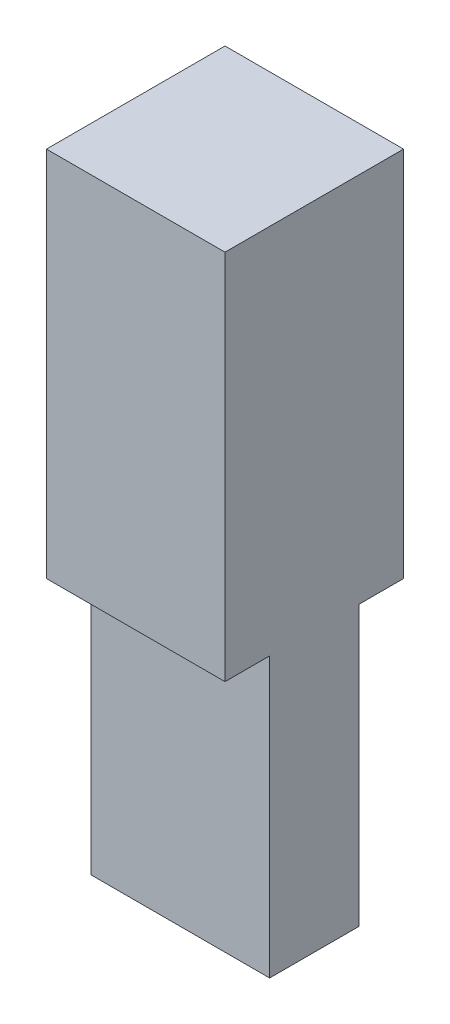
from build123d import *

# Parameters (mm, degrees)
BOSS_EXTRUDE1_DEPTH = 6.096


with BuildPart() as part:
    # Sketch2 → Boss-Extrude1 (new body)
    with BuildSketch(Plane(origin=(0, 0, 0), x_dir=(0, 0, -1), z_dir=(1, 0, 0))):
        Polygon((0, 0), (-1.524, 0), (-1.524, 9.525), (-3.048, 9.525), (-3.048, 22.225), (3.048, 22.225), (3.048, 9.525), (1.524, 9.525), (1.524, 0), align=None)
    extrude(amount=BOSS_EXTRUDE1_DEPTH)


solid = part.part
